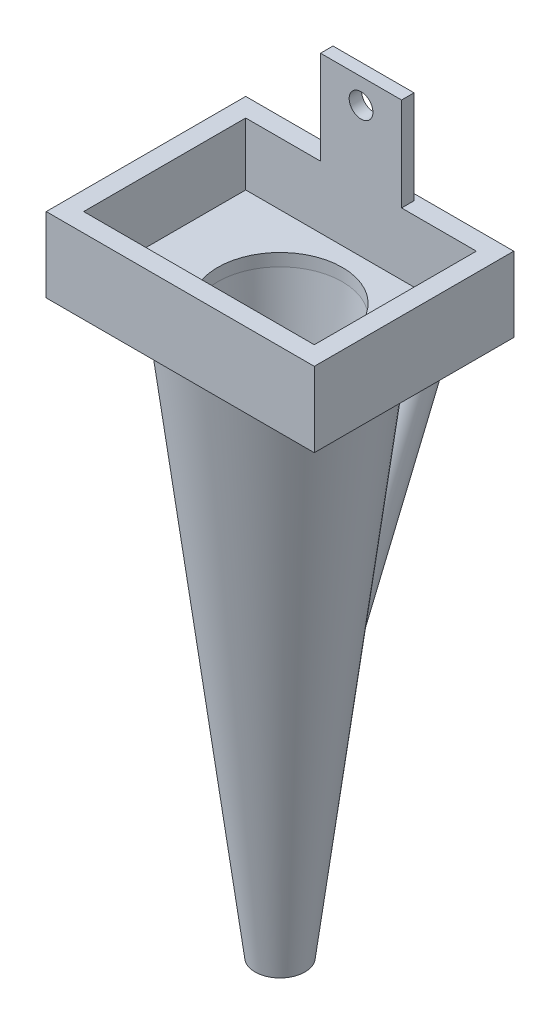
from build123d import *

# Parameters (mm, degrees)
SKETCH1_W           = 43
SKETCH1_H           = 32
SKETCH1_W_2         = 37
SKETCH1_H_2         = 26
BOSS_EXTRUDE1_DEPTH = 10
SKETCH2_W           = 13
SKETCH2_H           = 2
BOSS_EXTRUDE2_DEPTH = 15
CUT_EXTRUDE1_REACH  = 58.445
SKETCH3_R           = 1.905
SKETCH4_W           = 43
SKETCH4_H           = 32
BOSS_EXTRUDE3_DEPTH = 2
CUT_EXTRUDE2_REACH  = 58.303
SKETCH5_R           = 10
SKETCH14_R          = 3
BOSS_EXTRUDE4_DEPTH = 45
SKETCH16_R          = 2
CUT_EXTRUDE3_DEPTH  = 50


with BuildPart() as part:
    # Sketch1 → Boss-Extrude1 (new body)
    with BuildSketch(Plane(origin=(0, 0, 0), x_dir=(1, 0, 0), z_dir=(0, 1, 0))):
        with Locations((18.5, 13)):
            Rectangle(SKETCH1_W, SKETCH1_H)
        with Locations((18.5, 13)):
            Rectangle(SKETCH1_W_2, SKETCH1_H_2, mode=Mode.SUBTRACT)
    extrude(amount=BOSS_EXTRUDE1_DEPTH)

    # Sketch2 → Boss-Extrude2 (add)
    with BuildSketch(Plane(origin=(0, 10, 0), x_dir=(1, 0, 0), z_dir=(0, 1, 0))):
        with Locations((18.5, 27)):
            Rectangle(SKETCH2_W, SKETCH2_H)
    extrude(amount=BOSS_EXTRUDE2_DEPTH)

    # Sketch3 → Cut-Extrude1 (cut, up to next)
    with BuildSketch(Plane(origin=(0, 0, -28), x_dir=(-1, 0, 0), z_dir=(0, 0, -1)), mode=Mode.PRIVATE) as cut_extrude1_sk1:
        with Locations((-18.5, 21)):
            Circle(SKETCH3_R)
    cut_extrude1_tool1 = extrude(cut_extrude1_sk1.sketch, amount=-CUT_EXTRUDE1_REACH, mode=Mode.PRIVATE) & part.part
    add(cut_extrude1_tool1.solids().sort_by_distance((18.5, 21, -28))[0], mode=Mode.SUBTRACT)

    # Sketch4 → Boss-Extrude3 (add)
    with BuildSketch(Plane.XZ):
        with Locations((18.5, -13)):
            Rectangle(SKETCH4_W, SKETCH4_H)
    extrude(amount=BOSS_EXTRUDE3_DEPTH)

    # Sketch5 → Cut-Extrude2 (cut, up to next)
    with BuildSketch(Plane.XZ.offset(2), mode=Mode.PRIVATE) as cut_extrude2_sk1:
        with Locations((18.5, -13)):
            Circle(SKETCH5_R)
    cut_extrude2_tool1 = extrude(cut_extrude2_sk1.sketch, amount=-CUT_EXTRUDE2_REACH, mode=Mode.PRIVATE) & part.part
    add(cut_extrude2_tool1.solids().sort_by_distance((18.5, -2, -13))[0], mode=Mode.SUBTRACT)

    # Sketch9 → Revolve1 (revolve)
    with BuildSketch(Plane.XY.offset(-13)):
        Polygon((28.5, -2), (21.5, -90.9), (22.5, -90.9), (33.5, -2), align=None)
    revolve(axis=Axis((18.5, -2, -13), (0, -1, 0)))

    # Sketch14 → Boss-Extrude4 (add)
    with BuildSketch(Plane(origin=(18.5, -19.108562857, -35.499809934), x_dir=(-1, 0, 0), z_dir=(0, -0.9227821187332675, 0.38532215268025))):
        with Locations((0.305660396, 0)):
            Circle(SKETCH14_R)
    extrude(amount=BOSS_EXTRUDE4_DEPTH)

    # Sketch16 → Cut-Extrude3 (cut)
    with BuildSketch(Plane(origin=(0, -3.648843771, 1.523631969), x_dir=(1, 0, 0), z_dir=(0, 0.9227821187332675, -0.38532215268025005))):
        with Locations((18.194339604, 40.1215424)):
            Circle(SKETCH16_R)
    extrude(amount=-CUT_EXTRUDE3_DEPTH, mode=Mode.SUBTRACT)


solid = part.part
